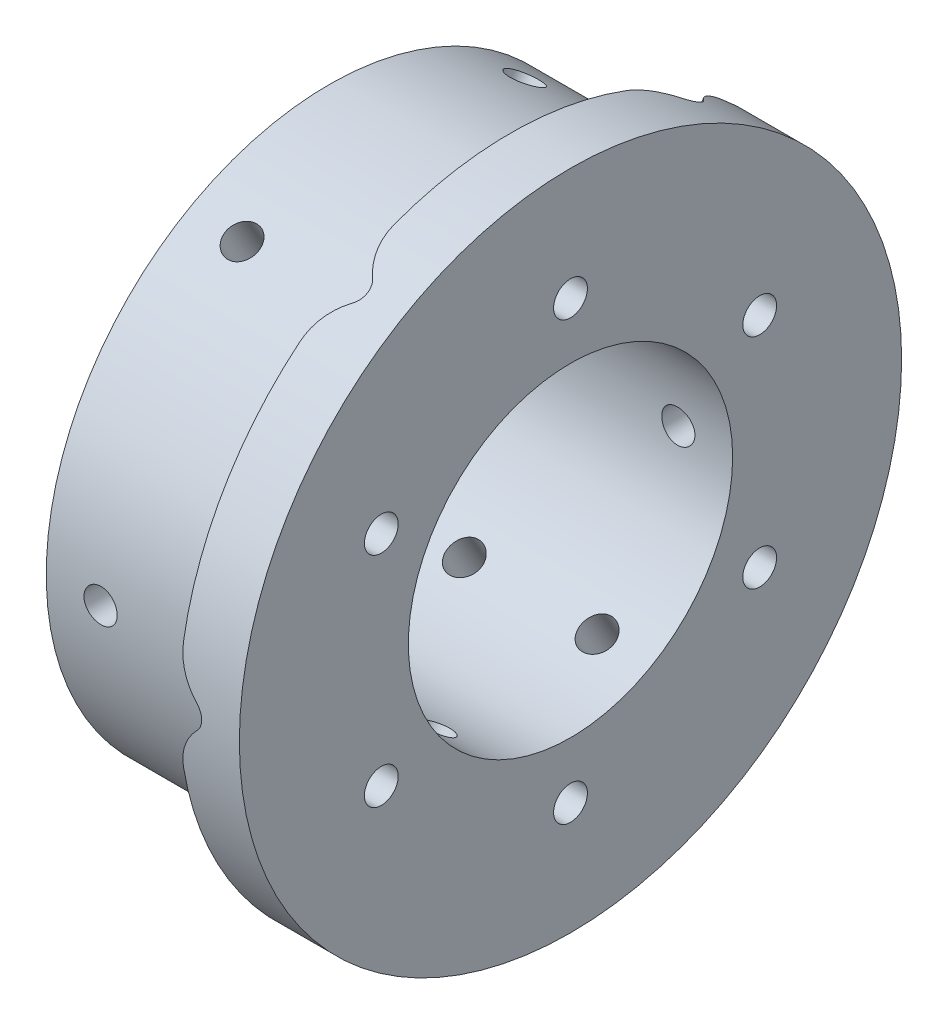
from build123d import *

# Parameters (mm, degrees)
SKETCH1_R                 = 23.435
SKETCH1_R_2               = 13.435
SKETCH1_R_3               = 1.4
BOSS_EXTRUDE1_DEPTH       = 10
SKETCH4_R                 = 27.435
SKETCH4_R_2               = 23.435
BOSS_EXTRUDE2_DEPTH       = 5
SKETCH3_R                 = 1.375
CUT_EXTRUDE1_DEPTH        = 28.435
CIRPATTERN1_COUNT         = 6
LPATTERN1_COUNT           = 2
LPATTERN1_PITCH           = 11
LPATTERN1_COPY_1_SKETCH_R = 1.375
LPATTERN1_COPY_1_DEPTH    = 28.435
LPATTERN1_COPY_2_SKETCH_R = 1.375
LPATTERN1_COPY_2_DEPTH    = 28.435
LPATTERN1_COPY_3_SKETCH_R = 1.375
LPATTERN1_COPY_3_DEPTH    = 28.435
LPATTERN1_COPY_4_SKETCH_R = 1.375
LPATTERN1_COPY_4_DEPTH    = 28.435
LPATTERN1_COPY_5_SKETCH_R = 1.375
LPATTERN1_COPY_5_DEPTH    = 28.435
FILLET1_R                 = 5


with BuildPart() as part:
    # Sketch1 → Boss-Extrude1 (new body, symmetric)
    with BuildSketch(Plane(origin=(0, 0, 0), x_dir=(0, 0, -1), z_dir=(1, 0, 0))):
        Circle(SKETCH1_R)
        Circle(SKETCH1_R_2, mode=Mode.SUBTRACT)
        with Locations((0, 18.1)):
            Circle(SKETCH1_R_3, mode=Mode.SUBTRACT)
        with Locations((15.675059808, 9.05)):
            Circle(SKETCH1_R_3, mode=Mode.SUBTRACT)
        with Locations((15.675059808, -9.05)):
            Circle(SKETCH1_R_3, mode=Mode.SUBTRACT)
        with Locations((0, -18.1)):
            Circle(SKETCH1_R_3, mode=Mode.SUBTRACT)
        with Locations((-15.675059808, -9.05)):
            Circle(SKETCH1_R_3, mode=Mode.SUBTRACT)
        with Locations((-15.675059808, 9.05)):
            Circle(SKETCH1_R_3, mode=Mode.SUBTRACT)
    extrude(amount=BOSS_EXTRUDE1_DEPTH, both=True)

    # Sketch4 → Boss-Extrude2 (add)
    with BuildSketch(Plane(origin=(10, 0, 0), x_dir=(0, 0, -1), z_dir=(1, 0, 0))):
        Circle(SKETCH4_R)
        Circle(SKETCH4_R_2, mode=Mode.SUBTRACT)
    extrude(amount=-BOSS_EXTRUDE2_DEPTH)

    # Sketch3 → Cut-Extrude1 (cut, through all)
    with BuildSketch(Plane.XY):
        with Locations((5.5, 0)):
            Circle(SKETCH3_R)
    cut_extrude1 = extrude(amount=-CUT_EXTRUDE1_DEPTH, mode=Mode.SUBTRACT)

    # CirPattern1: Cut-Extrude1 ×6 about axis
    cirpattern1_axis = Axis((10, 0, 0), (-1, 0, 0))
    for i in range(1, CIRPATTERN1_COUNT):
        add(cut_extrude1.rotate(cirpattern1_axis, i * 360 / CIRPATTERN1_COUNT), mode=Mode.SUBTRACT)

    # LPattern1: Cut-Extrude1 ×2
    with Locations(*[(-i * LPATTERN1_PITCH, 0, 0) for i in range(1, LPATTERN1_COUNT)]):
        add(cut_extrude1, mode=Mode.SUBTRACT)

    # LPattern1 copy 1 sketch → LPattern1 copy 1 (cut, through all)
    with BuildSketch(Plane(origin=(-11, 0, 0), x_dir=(1, 0, 0), z_dir=(0, 0.866025404, 0.5))):
        with Locations((5.5, 0)):
            Circle(LPATTERN1_COPY_1_SKETCH_R)
    extrude(amount=-LPATTERN1_COPY_1_DEPTH, mode=Mode.SUBTRACT)

    # LPattern1 copy 2 sketch → LPattern1 copy 2 (cut, through all)
    with BuildSketch(Plane(origin=(-11, 0, 0), x_dir=(1, 0, 0), z_dir=(0, 0.866025404, -0.5))):
        with Locations((5.5, 0)):
            Circle(LPATTERN1_COPY_2_SKETCH_R)
    extrude(amount=-LPATTERN1_COPY_2_DEPTH, mode=Mode.SUBTRACT)

    # LPattern1 copy 3 sketch → LPattern1 copy 3 (cut, through all)
    with BuildSketch(Plane(origin=(-11, 0, 0), x_dir=(1, 0, 0), z_dir=(0, 0, -1))):
        with Locations((5.5, 0)):
            Circle(LPATTERN1_COPY_3_SKETCH_R)
    extrude(amount=-LPATTERN1_COPY_3_DEPTH, mode=Mode.SUBTRACT)

    # LPattern1 copy 4 sketch → LPattern1 copy 4 (cut, through all)
    with BuildSketch(Plane(origin=(-11, 0, 0), x_dir=(1, 0, 0), z_dir=(0, -0.866025404, -0.5))):
        with Locations((5.5, 0)):
            Circle(LPATTERN1_COPY_4_SKETCH_R)
    extrude(amount=-LPATTERN1_COPY_4_DEPTH, mode=Mode.SUBTRACT)

    # LPattern1 copy 5 sketch → LPattern1 copy 5 (cut, through all)
    with BuildSketch(Plane(origin=(-11, 0, 0), x_dir=(1, 0, 0), z_dir=(0, -0.866025404, 0.5))):
        with Locations((5.5, 0)):
            Circle(LPATTERN1_COPY_5_SKETCH_R)
    extrude(amount=-LPATTERN1_COPY_5_DEPTH, mode=Mode.SUBTRACT)

    # Fillet1
    fillet1_edges = [part.edges().sort_by_distance(p)[0] for p in [
        (5, -1.280868846, -25.402526778),
        (5, 1.280868846, -25.402526778),
        (5, -21.358799087, 13.810528348),
        (5, -22.639667933, 11.59199843),
        (5, 1.280868846, 25.402526778),
        (5, -1.280868846, 25.402526778),
        (5, 22.639667933, 11.59199843),
        (5, 21.358799087, 13.810528348),
        (5, -21.358799087, -13.810528348),
        (5, -22.639667933, -11.59199843),
        (5, 21.358799087, -13.810528348),
        (5, 22.639667933, -11.59199843),
    ]]
    fillet(fillet1_edges, radius=FILLET1_R)


solid = part.part
